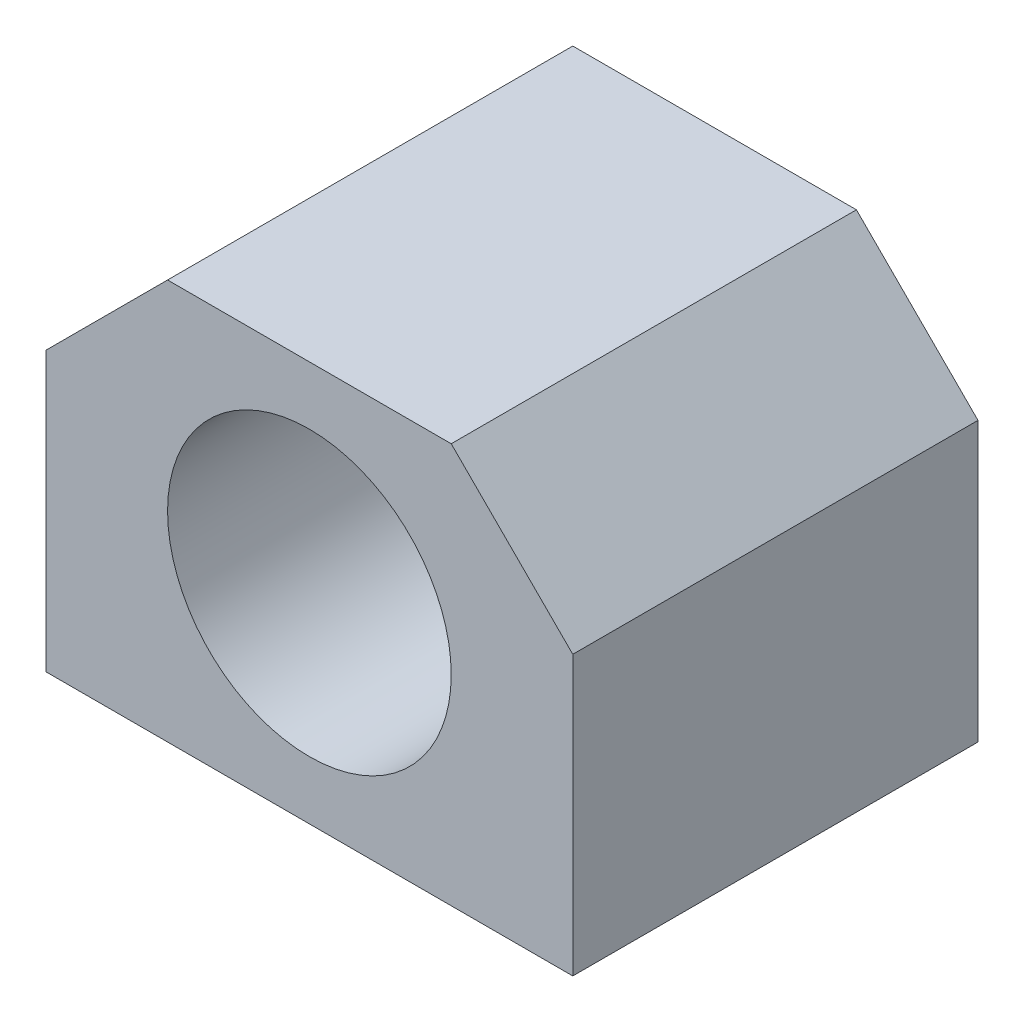
from build123d import *

# Parameters (mm, degrees)
SKETCH1_W           = 52
SKETCH1_H           = 39.5
SKETCH1_R           = 2.5
SKETCH1_R_2         = 14
BOSS_EXTRUDE1_DEPTH = 40
CHAMFER1_SIZE       = 12
SKETCH1_3_R         = 2.5
CUT_EXTRUDE1_DEPTH  = 16.5
SKETCH2_R           = 2.5
CUT_EXTRUDE2_DEPTH  = 8


with BuildPart() as part:
    # Sketch1 → Boss-Extrude1 (new body)
    with BuildSketch(Plane.XY):
        Rectangle(SKETCH1_W, SKETCH1_H)
        with Locations((13.258252147, 13.258252147)):
            Circle(SKETCH1_R, mode=Mode.SUBTRACT)
        with Locations((-13.258252147, 13.258252147)):
            Circle(SKETCH1_R, mode=Mode.SUBTRACT)
        with Locations((-18.75, 0)):
            Circle(SKETCH1_R, mode=Mode.SUBTRACT)
        with Locations((-13.258252147, -13.258252147)):
            Circle(SKETCH1_R, mode=Mode.SUBTRACT)
        with Locations((13.258252147, -13.258252147)):
            Circle(SKETCH1_R, mode=Mode.SUBTRACT)
        with Locations((18.75, 0)):
            Circle(SKETCH1_R, mode=Mode.SUBTRACT)
        Circle(SKETCH1_R_2, mode=Mode.SUBTRACT)
        with Locations((13.258252147, -13.258252147)):
            Circle(SKETCH1_R)
        with Locations((-13.258252147, -13.258252147)):
            Circle(SKETCH1_R)
        with Locations((-18.75, 0)):
            Circle(SKETCH1_R)
        with Locations((18.75, 0)):
            Circle(SKETCH1_R)
        with Locations((-13.258252147, 13.258252147)):
            Circle(SKETCH1_R)
        with Locations((13.258252147, 13.258252147)):
            Circle(SKETCH1_R)
    extrude(amount=BOSS_EXTRUDE1_DEPTH)

    # Chamfer1
    chamfer1_edges = [part.edges().sort_by_distance(p)[0] for p in [
        (-26, 19.75, 20),
        (26, 19.75, 20),
    ]]
    chamfer(chamfer1_edges, length=CHAMFER1_SIZE)

    # Sketch1_3 → Cut-Extrude1 (cut)
    with BuildSketch(Plane.XY):
        with Locations((13.258252147, 13.258252147)):
            Circle(SKETCH1_3_R)
        with Locations((18.75, 0)):
            Circle(SKETCH1_3_R)
        with Locations((13.258252147, -13.258252147)):
            Circle(SKETCH1_3_R)
        with Locations((-13.258252147, -13.258252147)):
            Circle(SKETCH1_3_R)
        with Locations((-18.75, 0)):
            Circle(SKETCH1_3_R)
        with Locations((-13.258252147, 13.258252147)):
            Circle(SKETCH1_3_R)
    extrude(amount=CUT_EXTRUDE1_DEPTH, mode=Mode.SUBTRACT)

    # Sketch2 → Cut-Extrude2 (cut)
    with BuildSketch(Plane.XZ.offset(19.75)):
        with Locations(Location((20, 8, 0), (0, 0, 270))):
            Circle(SKETCH2_R)
        with Locations(Location((-20, 8, 0), (0, 0, 270))):
            Circle(SKETCH2_R)
        with Locations(Location((20, 32, 0), (0, 0, 270))):
            Circle(SKETCH2_R)
        with Locations(Location((-20, 32, 0), (0, 0, 270))):
            Circle(SKETCH2_R)
    extrude(amount=-CUT_EXTRUDE2_DEPTH, mode=Mode.SUBTRACT)


solid = part.part
